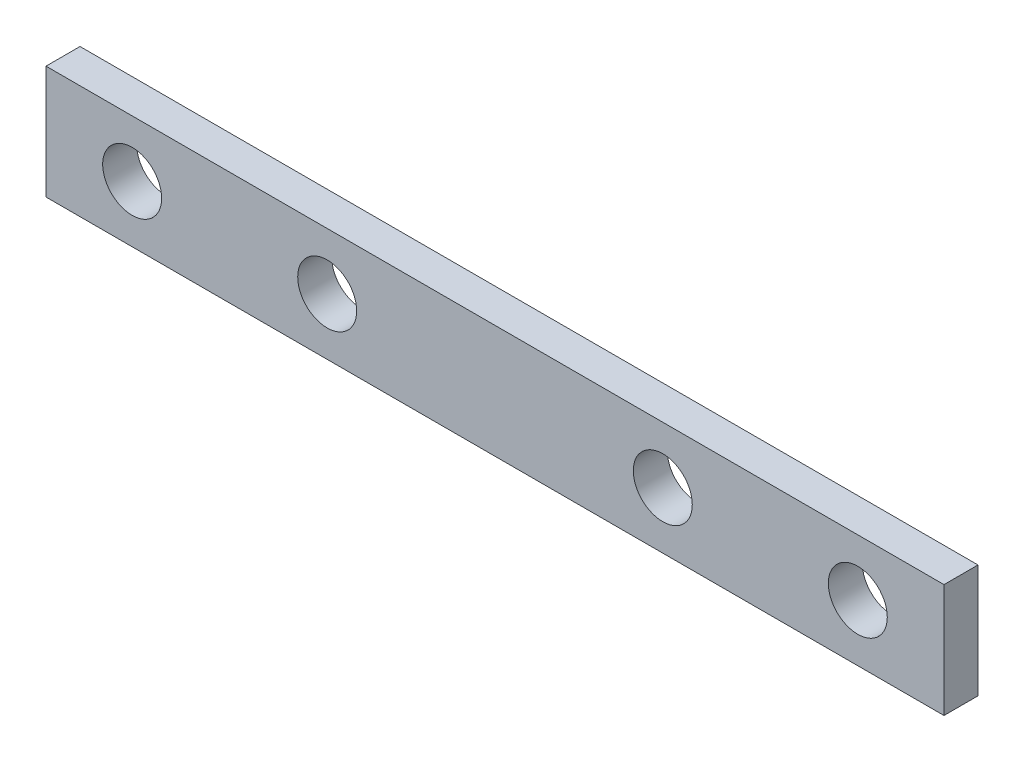
from build123d import *

# Parameters (mm, degrees)
SKETCH1_W           = 100.584
SKETCH1_H           = 12.7
SKETCH1_R           = 3.302
BOSS_EXTRUDE2_DEPTH = 3.81
CUT_EXTRUDE1_REACH  = 5.81
SKETCH2_R           = 3.302


with BuildPart() as part:
    # Sketch1 → Boss-Extrude2 (new body)
    with BuildSketch(Plane.XY):
        with Locations((-9.978006062, -18.390640797)):
            Rectangle(SKETCH1_W, SKETCH1_H)
        with Locations((30.661993938, -18.390640797)):
            Circle(SKETCH1_R, mode=Mode.SUBTRACT)
        with Locations((-50.618006062, -18.390640797)):
            Circle(SKETCH1_R, mode=Mode.SUBTRACT)
    extrude(amount=BOSS_EXTRUDE2_DEPTH)

    # Sketch2 → Cut-Extrude1 (cut, up to next)
    with BuildSketch(Plane(origin=(0, 0, 0), x_dir=(-1, 0, 0), z_dir=(0, 0, -1)), mode=Mode.PRIVATE) as cut_extrude1_sk1:
        with Locations((28.774006062, -18.390640797)):
            Circle(SKETCH2_R)
    cut_extrude1_tool1 = extrude(cut_extrude1_sk1.sketch, amount=-CUT_EXTRUDE1_REACH, mode=Mode.PRIVATE) & part.part
    add(cut_extrude1_tool1.solids().sort_by_distance((-28.774006, -18.390641, 0))[0], mode=Mode.SUBTRACT)
    # Sketch2 → Cut-Extrude1 (cut, up to next)
    with BuildSketch(Plane(origin=(0, 0, 0), x_dir=(-1, 0, 0), z_dir=(0, 0, -1)), mode=Mode.PRIVATE) as cut_extrude1_sk2:
        with Locations((-8.817993938, -18.390640797)):
            Circle(SKETCH2_R)
    cut_extrude1_tool2 = extrude(cut_extrude1_sk2.sketch, amount=-CUT_EXTRUDE1_REACH, mode=Mode.PRIVATE) & part.part
    add(cut_extrude1_tool2.solids().sort_by_distance((8.817994, -18.390641, 0))[0], mode=Mode.SUBTRACT)


solid = part.part
